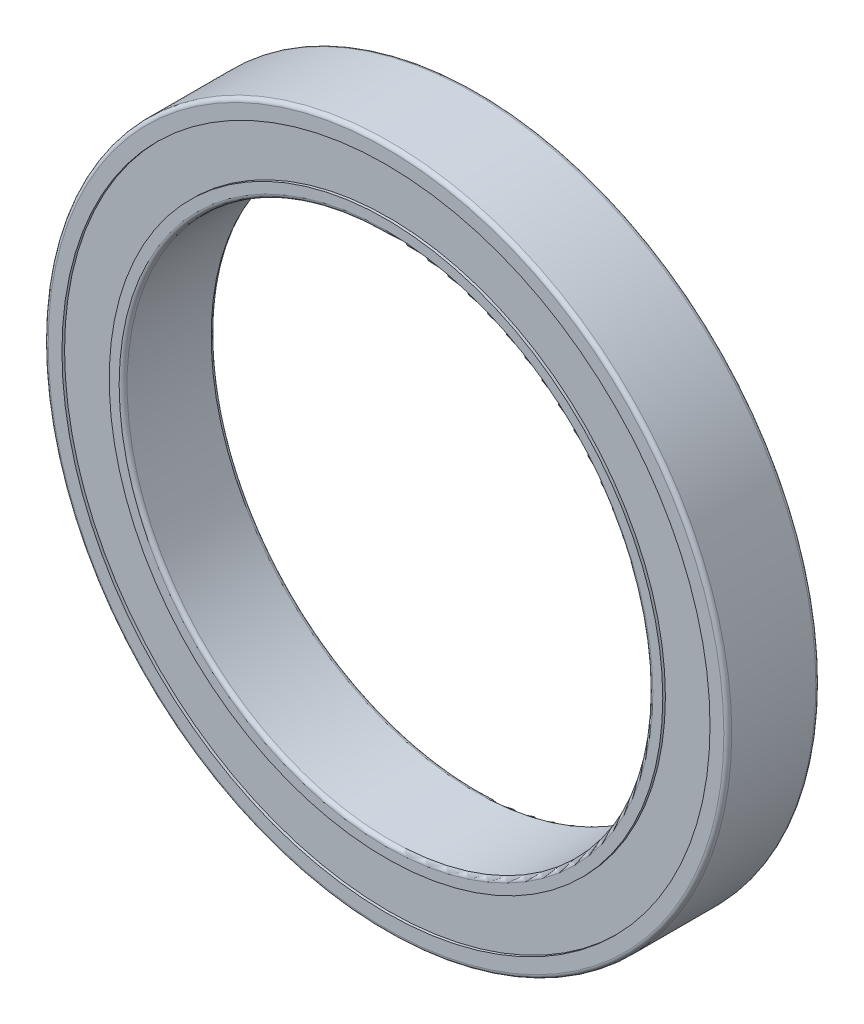
from build123d import *


with BuildPart() as part:
    # Sketch1 → Revolve1 (revolve)
    with BuildSketch(Plane(origin=(0, 0, 0), x_dir=(0, 0, -1), z_dir=(1, 0, 0))):
        with BuildLine():
            ThreePointArc((-3.640744937, 20.3), (-3.552876972, 20.087867966), (-3.340744937, 20))
            Line((-3.340744937, 20), (3.059255063, 20))
            ThreePointArc((3.059255063, 20), (3.271387097, 20.087867966), (3.359255063, 20.3))
            Line((3.359255063, 20.3), (3.359255063, 21.055000054))
            Line((3.359255063, 21.055000054), (3.159255063, 21.055000054))
            Line((3.159255063, 21.055000054), (3.159255063, 24.650000054))
            Line((3.159255063, 24.650000054), (3.359255063, 24.650000054))
            Line((3.359255063, 24.650000054), (3.359255063, 25.7))
            ThreePointArc((3.359255063, 25.7), (3.271387097, 25.912132034), (3.059255063, 26))
            Line((3.059255063, 26), (-3.340744937, 26))
            ThreePointArc((-3.340744937, 26), (-3.552876972, 25.912132034), (-3.640744937, 25.7))
            Line((-3.640744937, 25.7), (-3.640744937, 24.650000054))
            Line((-3.640744937, 24.650000054), (-3.440744937, 24.650000054))
            Line((-3.440744937, 24.650000054), (-3.440744937, 21.055000054))
            Line((-3.440744937, 21.055000054), (-3.640744937, 21.055000054))
            Line((-3.640744937, 21.055000054), (-3.640744937, 20.3))
        make_face()
    revolve(axis=Axis((0, 0, 0), (0, 0, -1)))


solid = part.part
